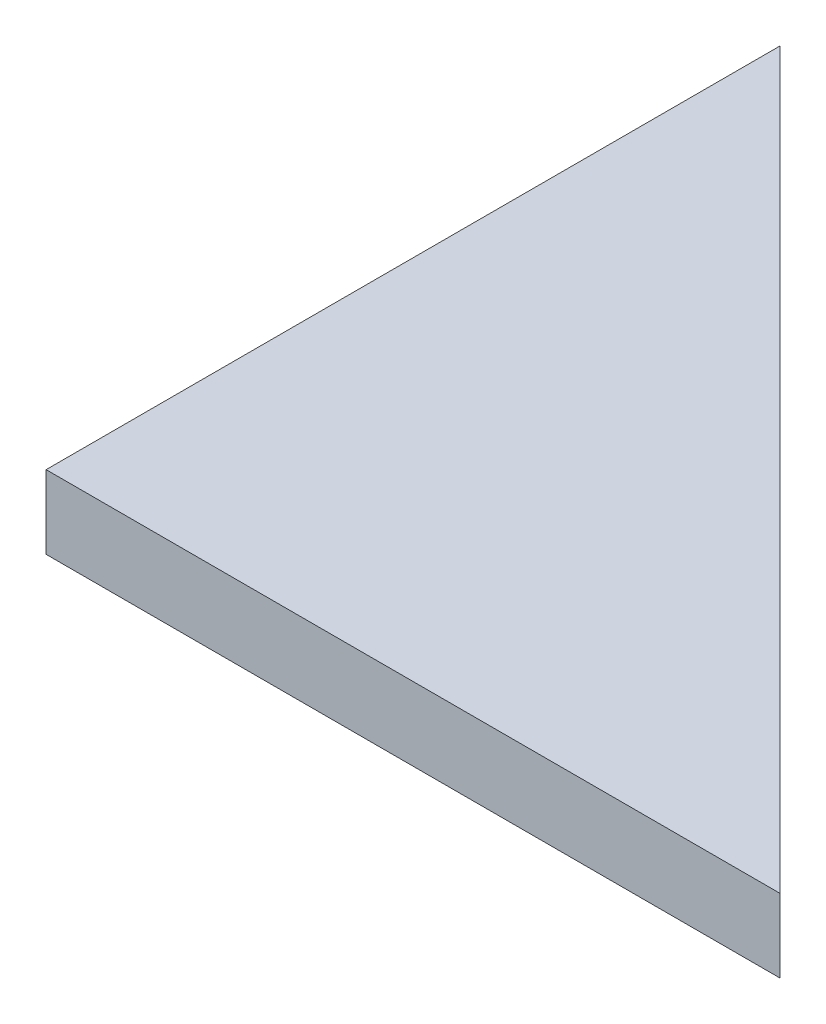
from build123d import *

# Parameters (mm, degrees)
BOSS_EXTRUDE1_DEPTH = 5


with BuildPart() as part:
    # Sketch1 → Boss-Extrude1 (new body)
    with BuildSketch(Plane(origin=(0, 0, 0), x_dir=(1, 0, 0), z_dir=(0, 1, 0))):
        Polygon((0, 0), (0, 50), (50, 0), align=None)
    extrude(amount=BOSS_EXTRUDE1_DEPTH)


solid = part.part
